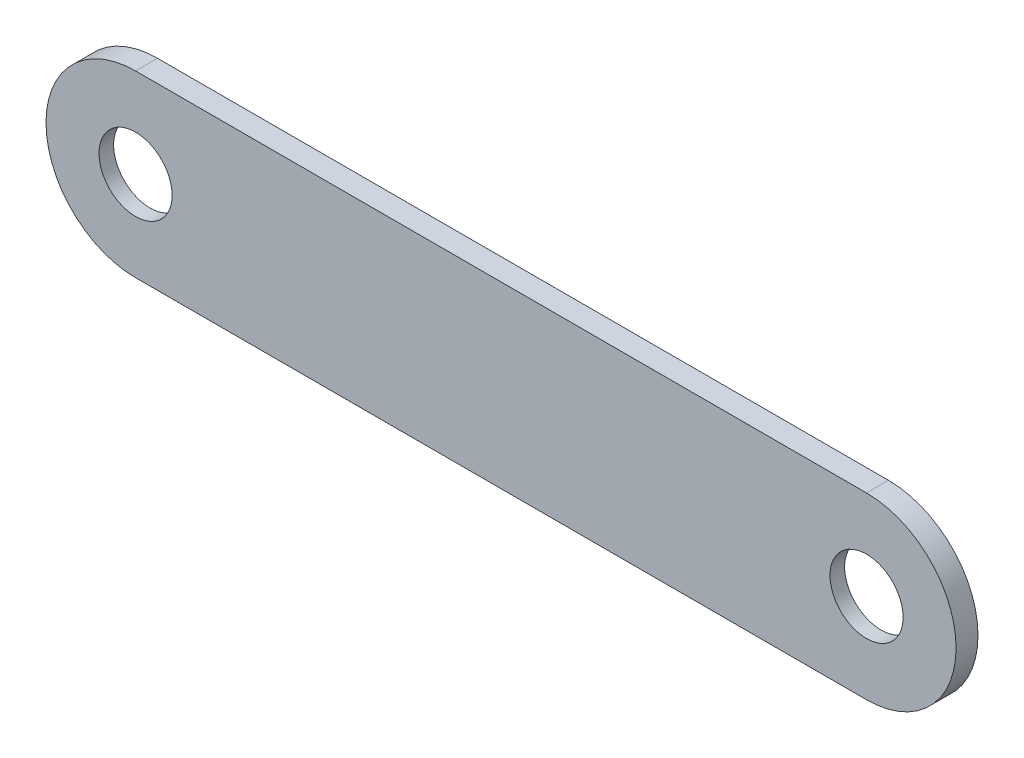
from build123d import *

# Parameters (mm, degrees)
SKETCH_1_R          = 5
EXTRUDE_1_DEPTH     = 3
SKETCH_4_R          = 7.5
CUT_EXTRUDE_3_DEPTH = 3


with BuildPart() as part:
    # 草图1 → 凸台-拉伸1 (new body)
    with BuildSketch(Plane.XY):
        with BuildLine():
            Line((0, 12.25), (100, 12.25))
            ThreePointArc((100, 12.25), (112.25, 0), (100, -12.25))
            Line((100, -12.25), (0, -12.25))
            ThreePointArc((0, -12.25), (-12.25, 0), (0, 12.25))
        make_face()
        Circle(SKETCH_1_R, mode=Mode.SUBTRACT)
        with Locations((100, 0)):
            Circle(SKETCH_1_R, mode=Mode.SUBTRACT)
    extrude(amount=EXTRUDE_1_DEPTH)

    # 草图4 → 切除-拉伸3 (cut)
    with BuildSketch(Plane.XY.offset(1)):
        Circle(SKETCH_4_R)
        with Locations((100, 0)):
            Circle(SKETCH_4_R)
    extrude(amount=-CUT_EXTRUDE_3_DEPTH, mode=Mode.SUBTRACT)


solid = part.part
